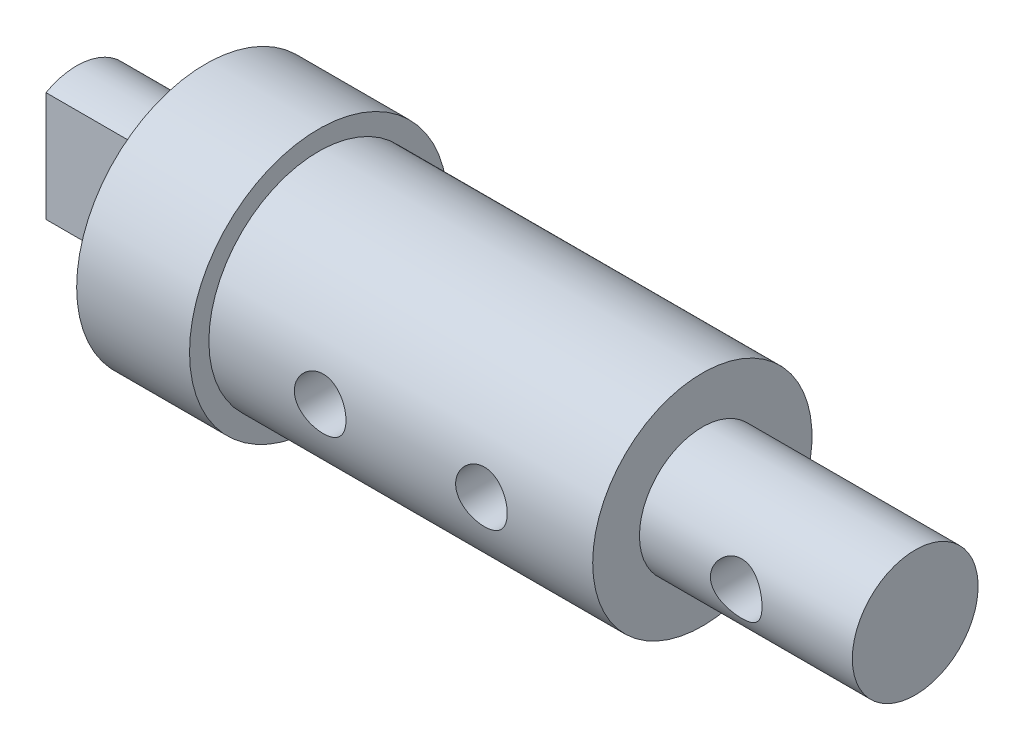
from build123d import *

# Parameters (mm, degrees)
M2X0_4_TAPPED_HOLE1_D           = 1.6
BOSS_EXTRUDE1_DEPTH             = 4
M2X0_4_TAPPED_HOLE2_D           = 1.6
M2X0_4_TAPPED_HOLE2_DEPTH       = 3
M2X0_4_TAPPED_HOLE2_CSINK_D     = 2.05
M2X0_4_TAPPED_HOLE2_CSINK_ANGLE = 90
M2X0_4_TAPPED_HOLE2_TIP         = 0.480688495
HOLE5_D                         = 1.8
HOLE5_DEPTH                     = 5


with BuildPart() as part:
    # Sketch1 → Revolve1 (revolve)
    with BuildSketch(Plane.XY):
        Polygon((-11, 0), (11, 0), (11, 1.95), (4.4, 1.95), (4.4, 3.4), (-7.5, 3.4), (-7.5, 4), (-11, 4), align=None)
    revolve(axis=Axis((0, 0, 0), (1, 0, 0)))

    # M2x0.4 Tapped Hole1 (through all)
    with Locations(Plane.XY.offset(3.4)):
        with Locations((-4.05, 0), (0.95, 0)):
            Hole(M2X0_4_TAPPED_HOLE1_D / 2)

    # Sketch6 → Boss-Extrude1 (add)
    with BuildSketch(Plane.ZY.offset(11)):
        with BuildLine():
            Line((0.95, 1.702938637), (0.95, -1.702938637))
            ThreePointArc((0.95, -1.702938637), (-1.95, 0), (0.95, 1.702938637))
        make_face()
    extrude(amount=BOSS_EXTRUDE1_DEPTH)

    # M2x0.4 Tapped Hole2
    with Locations(Plane.XY.offset(3.4)):
        with Locations((7.4, 0)):
            CounterSinkHole(M2X0_4_TAPPED_HOLE2_D / 2, M2X0_4_TAPPED_HOLE2_CSINK_D / 2, depth=M2X0_4_TAPPED_HOLE2_DEPTH, counter_sink_angle=M2X0_4_TAPPED_HOLE2_CSINK_ANGLE)
            with Locations((0, 0, -(M2X0_4_TAPPED_HOLE2_DEPTH + M2X0_4_TAPPED_HOLE2_TIP / 2))):  # 118° drill point
                Cone(0, M2X0_4_TAPPED_HOLE2_D / 2, M2X0_4_TAPPED_HOLE2_TIP, mode=Mode.SUBTRACT)

    # Hole5
    with Locations(Plane.ZY.offset(15)):
        with Locations((0, 0)):
            Hole(HOLE5_D / 2, depth=HOLE5_DEPTH)


solid = part.part
